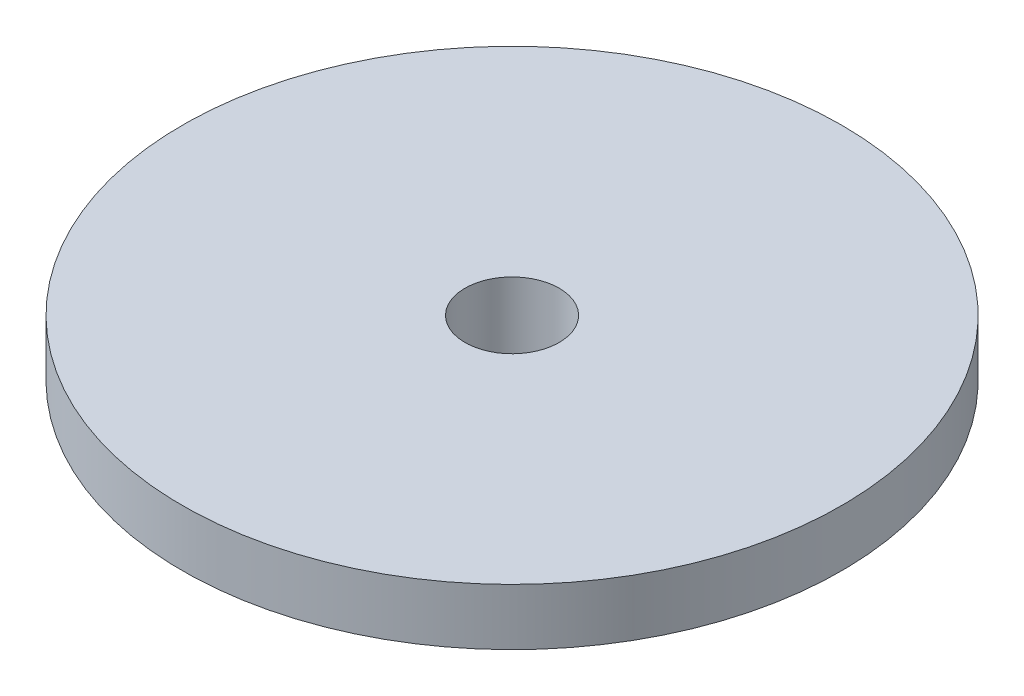
from build123d import *

# Parameters (mm, degrees)
SKETCH10_R         = 2.5
CUT_EXTRUDE1_DEPTH = 11


with BuildPart() as part:
    # Sketch1 → Revolve1 (revolve)
    with BuildSketch(Plane.XY):
        Polygon((0, 0), (0, 10), (17.5, 10), (17.5, 7), (7, 0), align=None)
    revolve(axis=Axis((0, 0, 0), (0, 1, 0)))

    # Sketch10 → Cut-Extrude1 (cut, through all)
    with BuildSketch(Plane.XZ):
        Circle(SKETCH10_R)
    extrude(amount=-CUT_EXTRUDE1_DEPTH, mode=Mode.SUBTRACT)


solid = part.part
